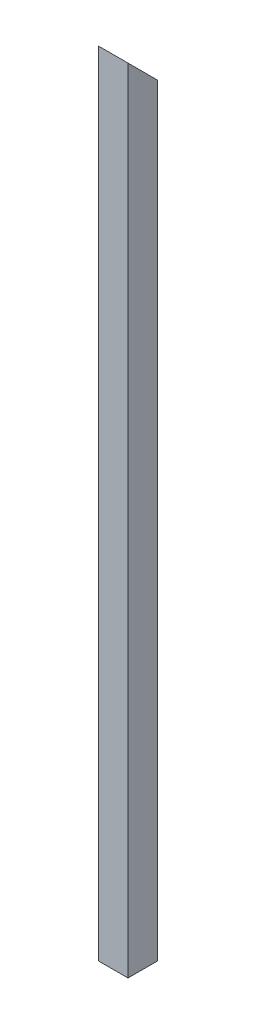
from build123d import *

# Parameters (mm, degrees)
SKETCH1_W           = 19.05
SKETCH1_H           = 19.05
BOSS_EXTRUDE1_DEPTH = 533.4
CUT_EXTRUDE1_DEPTH  = 20.05


with BuildPart() as part:
    # Sketch1 → Boss-Extrude1 (new body)
    with BuildSketch(Plane(origin=(0, 0, 0), x_dir=(1, 0, 0), z_dir=(0, 1, 0))):
        Rectangle(SKETCH1_W, SKETCH1_H)
    extrude(amount=BOSS_EXTRUDE1_DEPTH)

    # Sketch4 → Cut-Extrude1 (cut, through all)
    with BuildSketch(Plane(origin=(9.525, 0, 0), x_dir=(0, 0, -1), z_dir=(1, 0, 0))):
        Polygon((9.525, 491.735111143), (-9.525, 510.785111143), (-9.525, 533.4), (9.525, 533.4), align=None)
    extrude(amount=-CUT_EXTRUDE1_DEPTH, mode=Mode.SUBTRACT)


solid = part.part
